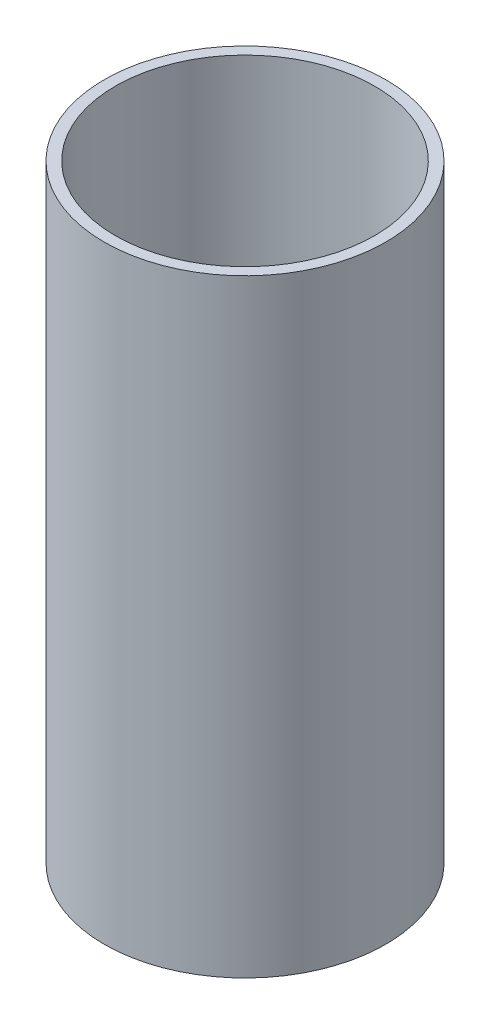
from build123d import *

# Parameters (mm, degrees)
SKETCH1_R                = 19
SKETCH1_R_2              = 17.5
BOSS_EXTRUDE1_DEPTH      = 80.1
RESSALTO_EXTRUS_O1_START = -2
SKETCH1_2_R              = 19
RESSALTO_EXTRUS_O1_DEPTH = 2


with BuildPart() as part:
    # Sketch1 → Boss-Extrude1 (new body)
    with BuildSketch(Plane(origin=(0, 0, 0), x_dir=(1, 0, 0), z_dir=(0, 1, 0))):
        Circle(SKETCH1_R)
        Circle(SKETCH1_R_2, mode=Mode.SUBTRACT)
    extrude(amount=BOSS_EXTRUDE1_DEPTH)

    # Sketch1_2 → Ressalto-extrus_o1 (add)
    with BuildSketch(Plane(origin=(0, 0, 0), x_dir=(1, 0, 0), z_dir=(0, 1, 0)).offset(RESSALTO_EXTRUS_O1_START)):
        Circle(SKETCH1_2_R)
    extrude(amount=RESSALTO_EXTRUS_O1_DEPTH)


solid = part.part
